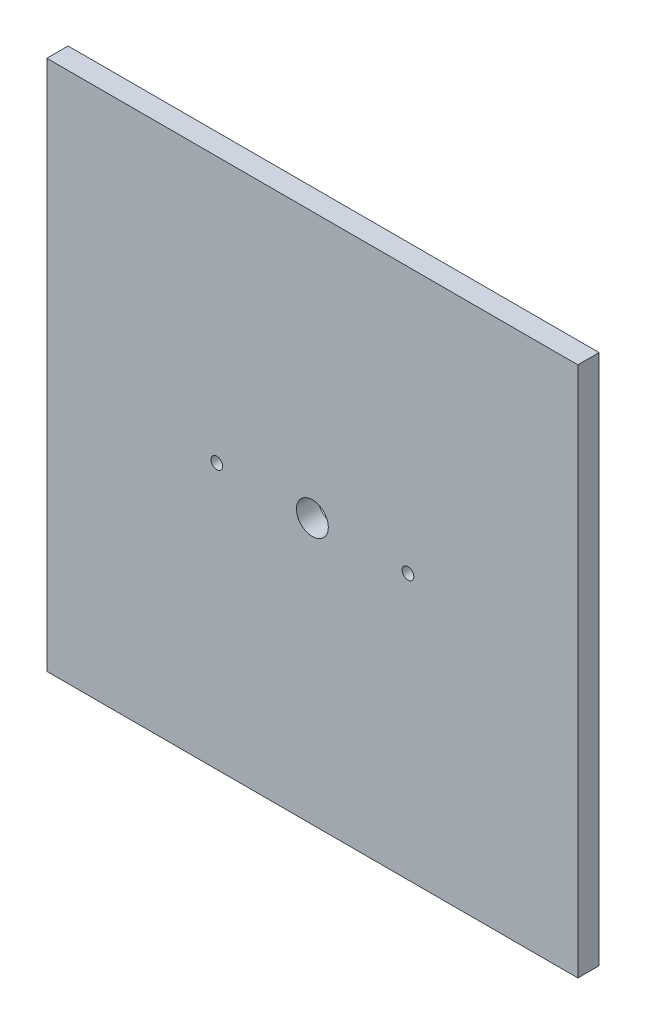
from build123d import *

# Parameters (mm, degrees)
SKIZZE1_W                        = 250
SKIZZE1_H                        = 250
AUFSATZ_LINEAR_AUSTRAGEN1_DEPTH  = 10
F_5_5_5_5_DURCHMESSER_BOHRUNG1_D = 5.5
F_15_0_15_DURCHMESSER_BOHRUNG1_D = 15


with BuildPart() as part:
    # Skizze1 → Aufsatz-Linear austragen1 (new body)
    with BuildSketch(Plane.XY):
        Rectangle(SKIZZE1_W, SKIZZE1_H)
    extrude(amount=AUFSATZ_LINEAR_AUSTRAGEN1_DEPTH)

    # Ø5.5 (5.5) Durchmesser Bohrung1 (through all)
    with Locations(Plane.XY.offset(10)):
        with Locations((45, 0), (-45, 0)):
            Hole(F_5_5_5_5_DURCHMESSER_BOHRUNG1_D / 2)

    # Ø15.0 (15) Durchmesser Bohrung1 (through all)
    with Locations(Plane.XY.offset(10)):
        with Locations((0, 0)):
            Hole(F_15_0_15_DURCHMESSER_BOHRUNG1_D / 2)


solid = part.part
